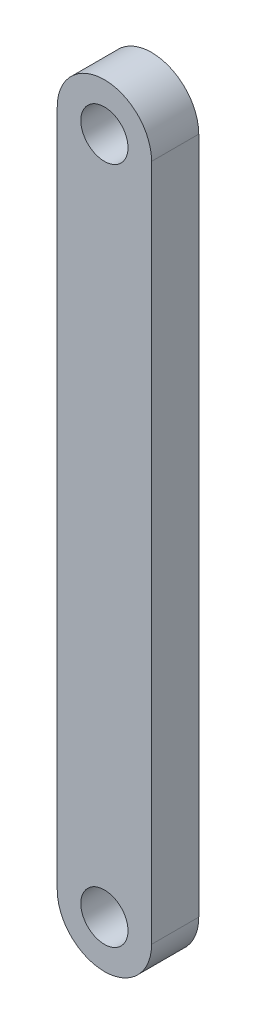
from build123d import *

# Parameters (mm, degrees)
BOSS_EXTRUDE1_DEPTH = 4
SKETCH2_R           = 4
CUT_EXTRUDE1_DEPTH  = 9


with BuildPart() as part:
    # Sketch1 → Boss-Extrude1 (new body, symmetric)
    with BuildSketch(Plane.XY):
        with BuildLine():
            Line((0, 0), (0, 115))
            ThreePointArc((0, 115), (8, 123), (16, 115))
            Line((16, 115), (16, 0))
            ThreePointArc((16, 0), (8, -8), (0, 0))
        make_face()
    extrude(amount=BOSS_EXTRUDE1_DEPTH, both=True)

    # Sketch2 → Cut-Extrude1 (cut, through all)
    with BuildSketch(Plane.XY.offset(4)):
        with Locations((8, 115)):
            Circle(SKETCH2_R)
        with Locations((8, 0)):
            Circle(SKETCH2_R)
    extrude(amount=-CUT_EXTRUDE1_DEPTH, mode=Mode.SUBTRACT)


solid = part.part
